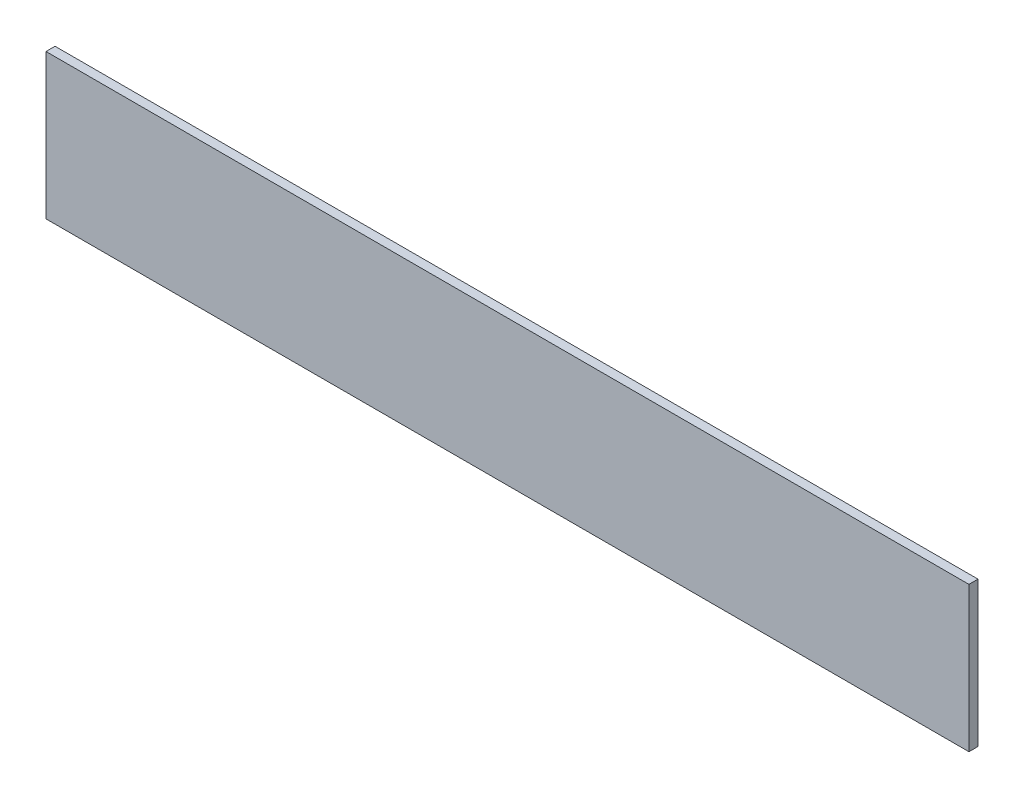
from build123d import *

# Parameters (mm, degrees)
SKETCH1_W           = 646.866076921
SKETCH1_H           = 101.6
BOSS_EXTRUDE1_DEPTH = 6.35


with BuildPart() as part:
    # Sketch1 → Boss-Extrude1 (new body)
    with BuildSketch(Plane.XY):
        with Locations((323.433038461, 50.8)):
            Rectangle(SKETCH1_W, SKETCH1_H)
    extrude(amount=BOSS_EXTRUDE1_DEPTH)


solid = part.part
